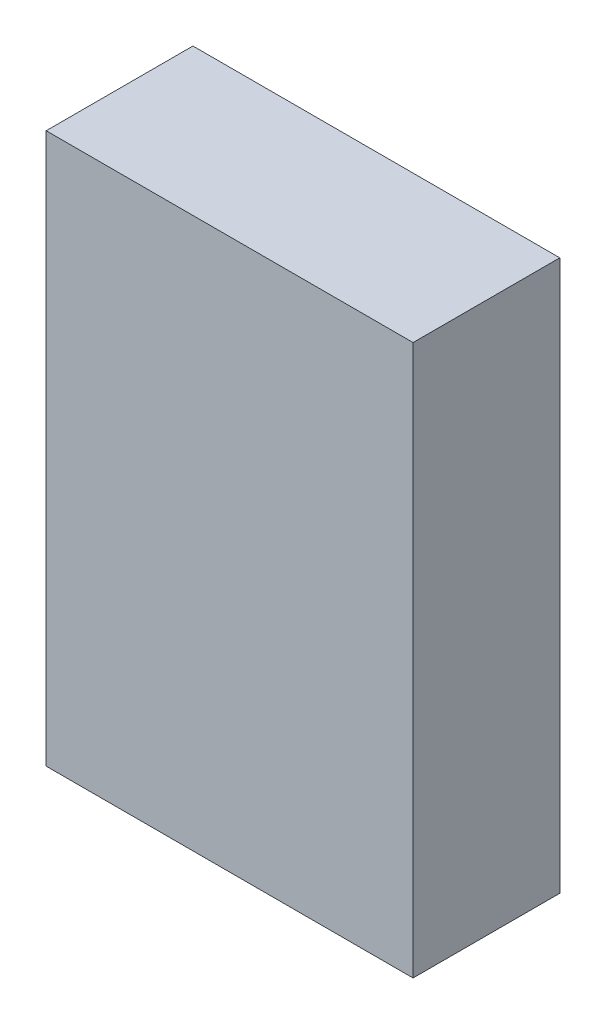
from build123d import *

# Parameters (mm, degrees)
SKETCH1_W           = 50
SKETCH1_H           = 75
BOSS_EXTRUDE1_DEPTH = 20


with BuildPart() as part:
    # Sketch1 → Boss-Extrude1 (new body)
    with BuildSketch(Plane.XY):
        with Locations((25, 37.5)):
            Rectangle(SKETCH1_W, SKETCH1_H)
    extrude(amount=BOSS_EXTRUDE1_DEPTH)


solid = part.part
